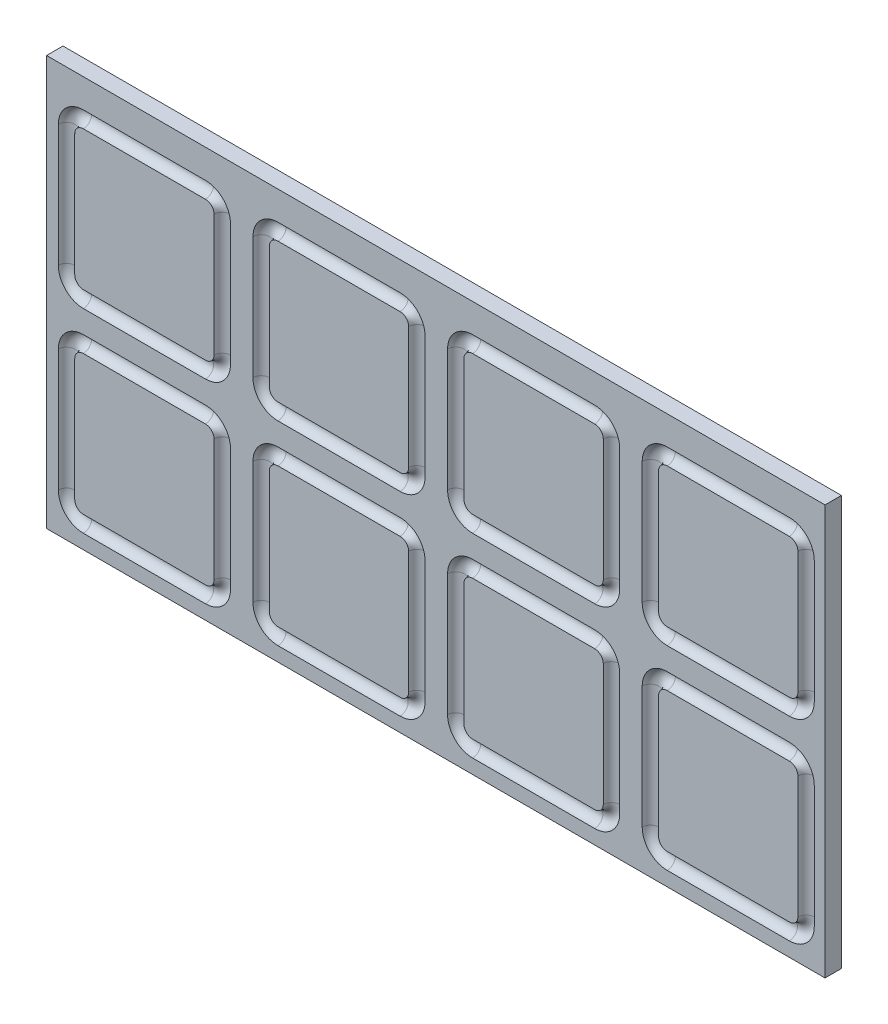
from build123d import *

# Parameters (mm, degrees)
SKETCH3_W            = 380
SKETCH3_H            = 200
BOSS_EXTRUDE1_DEPTH  = 8
SKETCH6_R            = 4
LPATTERN1_COUNT      = 4
LPATTERN1_PITCH      = 95
LPATTERN1_COUNT_DIR2 = 2
LPATTERN1_PITCH_DIR2 = 95


with BuildPart() as part:
    # Sketch3 → Boss-Extrude1 (new body)
    with BuildSketch(Plane.XY):
        with Locations((142.248096053, -43.976633958)):
            Rectangle(SKETCH3_W, SKETCH3_H)
    extrude(amount=-BOSS_EXTRUDE1_DEPTH)

    # Cut-Sweep11: sweep along a path in Sketch1
    with BuildLine(Plane.XY) as cut_sweep11_path:
        Line((29.8, 38), (-29.8, 38))
        ThreePointArc((-29.8, 38), (-35.598275606, 35.598275606), (-38, 29.8))
        Line((-38, 29.8), (-38, -29.8))
        ThreePointArc((-38, -29.8), (-35.598275606, -35.598275606), (-29.8, -38))
        Line((-29.8, -38), (29.8, -38))
        ThreePointArc((29.8, -38), (35.598275606, -35.598275606), (38, -29.8))
        Line((38, -29.8), (38, 29.8))
        ThreePointArc((38, 29.8), (35.598275606, 35.598275606), (29.8, 38))
    # Sketch6 → Cut-Sweep11 (sweep, cut)
    with BuildSketch(Plane(origin=(0, 0, 0), x_dir=(1, 0, 0), z_dir=(0, 1, 0))):
        with Locations((-38, 0)):
            Circle(SKETCH6_R)
    cut_sweep11 = sweep(path=cut_sweep11_path.line, mode=Mode.SUBTRACT)

    # LPattern1: Cut-Sweep11 4 × 2
    with Locations(*[(i * LPATTERN1_PITCH, -j * LPATTERN1_PITCH_DIR2, 0) for i in range(LPATTERN1_COUNT) for j in range(LPATTERN1_COUNT_DIR2) if (i, j) != (0, 0)]):
        add(cut_sweep11, mode=Mode.SUBTRACT)


solid = part.part
